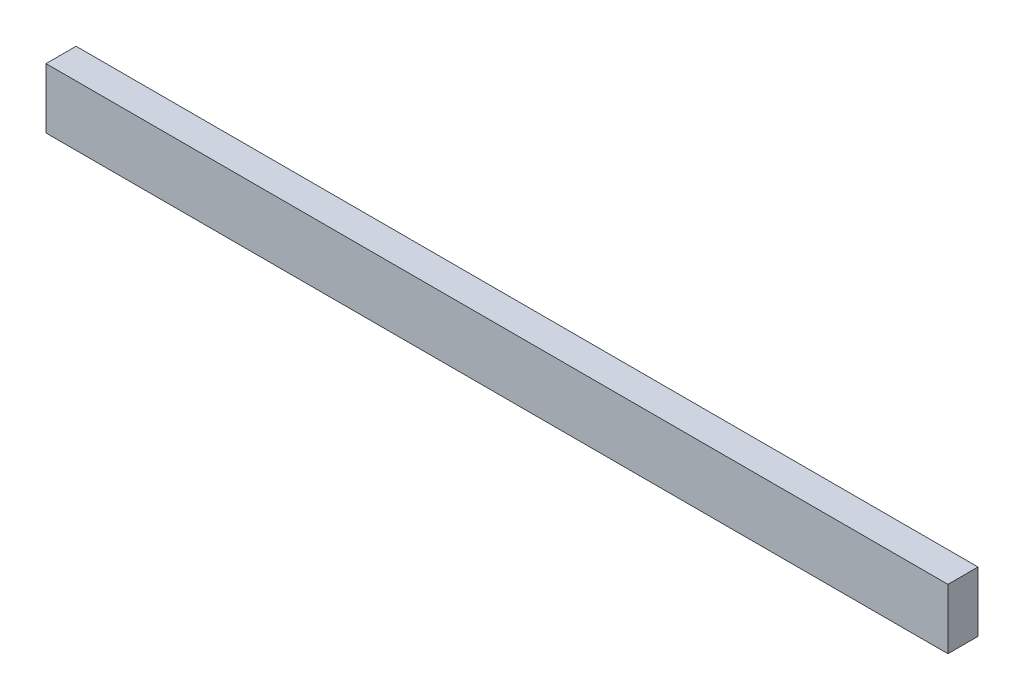
from build123d import *

# Parameters (mm, degrees)
SKETCH1_W           = 30
SKETCH1_H           = 2
BOSS_EXTRUDE1_DEPTH = 1


with BuildPart() as part:
    # Sketch1 → Boss-Extrude1 (new body)
    with BuildSketch(Plane.XY):
        Rectangle(SKETCH1_W, SKETCH1_H)
    extrude(amount=BOSS_EXTRUDE1_DEPTH)


solid = part.part
